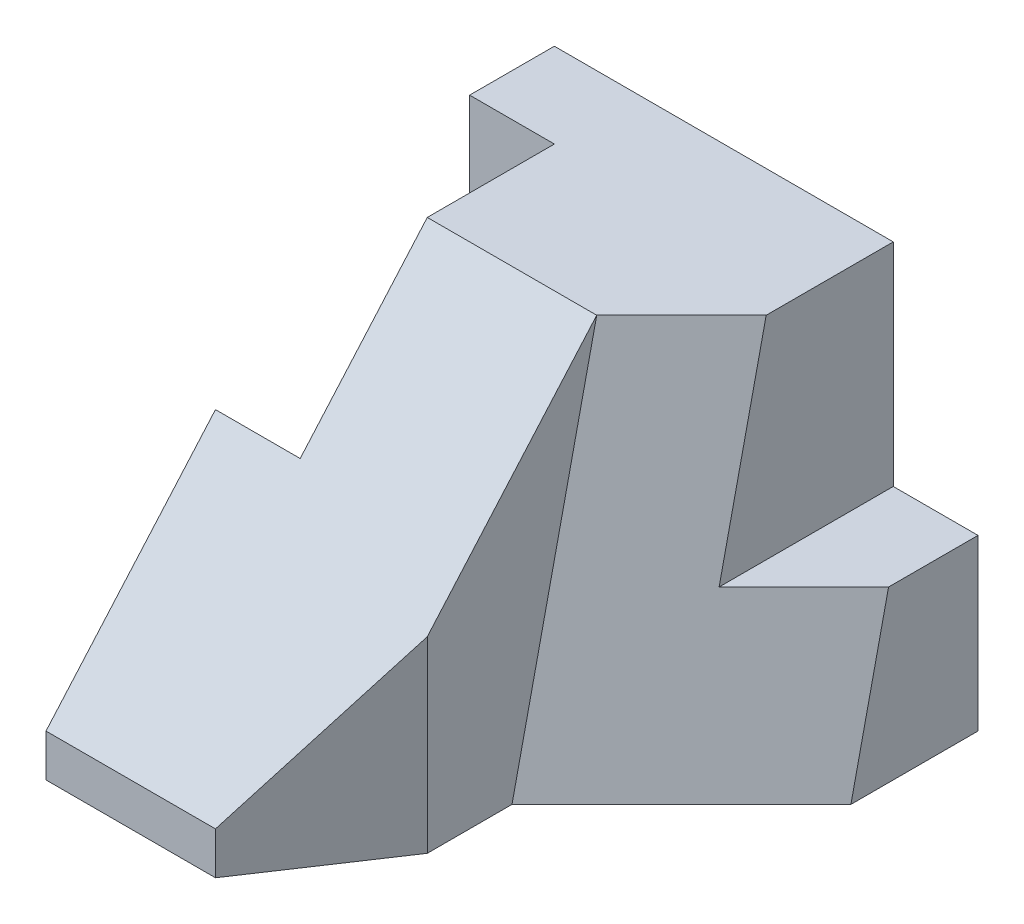
from build123d import *

# Parameters (mm, degrees)
SKETCH1_W            = 80
SKETCH1_H            = 50
BOSS_EXTRUDE1_DEPTH  = 90
SKETCH2_W            = 20
SKETCH2_H            = 30
CUT_EXTRUDE1_DEPTH   = 90
BOSS_EXTRUDE2_DEPTH  = 20
CUT_EXTRUDE2_DEPTH   = 127
BOSS_EXTRUDE10_DEPTH = 38
BOSS_EXTRUDE16_DEPTH = 38
BOSS_EXTRUDE17_DEPTH = 38
SKETCH13_W           = 30
SKETCH13_H           = 50
CUT_EXTRUDE4_DEPTH   = 38
SKETCH14_W           = 100
SKETCH14_H           = 90
CUT_EXTRUDE5_DEPTH   = 38
SKETCH15_W           = 106.776830175
SKETCH15_H           = 78.518203409
CUT_EXTRUDE6_DEPTH   = 38
BOSS_EXTRUDE18_DEPTH = 10
CUT_EXTRUDE7_DEPTH   = 10
BOSS_EXTRUDE19_DEPTH = 112
SKETCH19_W           = 80
SKETCH19_H           = 90
CUT_EXTRUDE8_DEPTH   = 112
SKETCH20_W           = 107.666200856
SKETCH20_H           = 176.074092784
CUT_EXTRUDE9_DEPTH   = 112
SKETCH21_W           = 20
SKETCH21_H           = 60
CUT_EXTRUDE10_DEPTH  = 112
SKETCH27_W           = 22.568644797
SKETCH27_H           = 9.839278278
BOSS_EXTRUDE22_DEPTH = 20
BOSS_EXTRUDE24_DEPTH = 91
SKETCH32_W           = 16.460176991
SKETCH32_H           = 60
CUT_EXTRUDE13_DEPTH  = 101
CUT_EXTRUDE14_DEPTH  = 101
BOSS_EXTRUDE25_DEPTH = 5
SKETCH35_W           = 20
SKETCH35_H           = 60
CUT_EXTRUDE15_DEPTH  = 152
BOSS_EXTRUDE27_DEPTH = 20
SKETCH42_W           = 25
SKETCH42_H           = 10
BOSS_EXTRUDE29_DEPTH = 20
BOSS_EXTRUDE30_DEPTH = 20
BOSS_EXTRUDE31_DEPTH = 20
SKETCH46_W           = 60
SKETCH46_H           = 50
CUT_EXTRUDE19_DEPTH  = 20
CUT_EXTRUDE20_DEPTH  = 20
CUT_EXTRUDE21_DEPTH  = 10


with BuildPart() as part:
    # Sketch1 → Boss-Extrude1 (new body)
    with BuildSketch(Plane(origin=(0, 0, 0), x_dir=(1, 0, 0), z_dir=(0, 1, 0))):
        with Locations((40, 25)):
            Rectangle(SKETCH1_W, SKETCH1_H)
    extrude(amount=BOSS_EXTRUDE1_DEPTH)

    # Sketch2 → Cut-Extrude1 (cut)
    with BuildSketch(Plane(origin=(0, 90, 0), x_dir=(1, 0, 0), z_dir=(0, 1, 0))):
        with Locations((10, 15)):
            Rectangle(SKETCH2_W, SKETCH2_H)
    extrude(amount=-CUT_EXTRUDE1_DEPTH, mode=Mode.SUBTRACT)

    # Sketch3 → Boss-Extrude2 (add)
    with BuildSketch(Plane(origin=(80, 0, 0), x_dir=(0, 0, -1), z_dir=(1, 0, 0))):
        Polygon((20, 0), (50, 0), (50, 40), (30, 40), align=None)
    extrude(amount=BOSS_EXTRUDE2_DEPTH)

    # Sketch4 → Cut-Extrude2 (cut)
    with BuildSketch(Plane(origin=(0, 90, 0), x_dir=(1, 0, 0), z_dir=(0, 1, 0))):
        Polygon((60, 0), (80, 20), (80, 0), align=None)
    extrude(amount=-CUT_EXTRUDE2_DEPTH, mode=Mode.SUBTRACT)

    # Sketch7 → Boss-Extrude10 (add)
    with BuildSketch(Plane(origin=(38.787878788, 9.696969697, 38.787878788), x_dir=(0.717740563, -0.168880132, -0.675520529), z_dir=(0.696310624, 0.174077656, 0.696310624))):
        Polygon((29.554023164, -4.850712501), (85.284466846, 4.850712501), (85.284466846, 46.081768757), align=None)
    extrude(amount=-BOSS_EXTRUDE10_DEPTH)

    # Sketch10 → Boss-Extrude16 (add)
    with BuildSketch(Plane(origin=(39.036144578, 8.674698795, 39.036144578), x_dir=(0.715575428, -0.15153362, -0.68190129), z_dir=(0.698535473, 0.155230105, 0.698535473))):
        Polygon((57.246034218, 92.195444573), (15.321732688, 85.687530838), (29.296499865, -4.338609156), (85.195568572, 4.338609156), (85.195568572, 46.23657111), align=None)
    extrude(amount=-BOSS_EXTRUDE16_DEPTH)

    # Sketch11 → Boss-Extrude17 (add)
    with BuildSketch(Plane(origin=(100, 0, 0), x_dir=(0, 0, -1), z_dir=(1, 0, 0))):
        Polygon((20, 0), (29.088944068, 40.900248307), (30, 40), align=None)
    extrude(amount=-BOSS_EXTRUDE17_DEPTH)

    # Sketch13 → Cut-Extrude4 (cut)
    with BuildSketch(Plane(origin=(80, 0, 0), x_dir=(0, 0, -1), z_dir=(1, 0, 0))):
        with Locations((35, 65)):
            Rectangle(SKETCH13_W, SKETCH13_H)
    extrude(amount=CUT_EXTRUDE4_DEPTH, mode=Mode.SUBTRACT)

    # Sketch14 → Cut-Extrude5 (cut)
    with BuildSketch(Plane(origin=(0, 0, -50), x_dir=(-1, 0, 0), z_dir=(0, 0, -1))):
        with Locations((-50, 45)):
            Rectangle(SKETCH14_W, SKETCH14_H)
    extrude(amount=CUT_EXTRUDE5_DEPTH, mode=Mode.SUBTRACT)

    # Sketch15 → Cut-Extrude6 (cut)
    with BuildSketch(Plane.XZ):
        with Locations((53.388415088, -10.740898295)):
            Rectangle(SKETCH15_W, SKETCH15_H)
    extrude(amount=CUT_EXTRUDE6_DEPTH, mode=Mode.SUBTRACT)

    # Sketch16 → Boss-Extrude18 (add)
    with BuildSketch(Plane(origin=(0, 0, 0), x_dir=(-1, 0, 0), z_dir=(0, -1, 0))):
        Polygon((-60, -20), (-60, -40), (-40, -70), (0, -70), (0, -30), (-20, -30), (-20, 0), (-40, 0), align=None)
    extrude(amount=-BOSS_EXTRUDE18_DEPTH)

    # Sketch17 → Cut-Extrude7 (cut)
    with BuildSketch(Plane(origin=(0, 39.026548673, 44.601769912), x_dir=(-1, 0, 0), z_dir=(0, -0.658504608, -0.752576695))):
        Polygon((-20, 67.731902524), (0, -38.569555604), (-40, -38.569555604), (-60, 67.731902524), align=None)
    extrude(amount=-CUT_EXTRUDE7_DEPTH, mode=Mode.SUBTRACT)

    # Sketch18 → Boss-Extrude19 (add)
    with BuildSketch(Plane(origin=(0, 39.026548673, 44.601769912), x_dir=(-1, 0, 0), z_dir=(0, -0.658504608, -0.752576695))):
        Polygon((-20, 67.731902524), (-60, 67.731902524), (-40, -38.569555604), (0, -38.569555604), align=None)
    extrude(amount=BOSS_EXTRUDE19_DEPTH)

    # Sketch19 → Cut-Extrude8 (cut)
    with BuildSketch(Plane(origin=(0, 0, -50), x_dir=(-1, 0, 0), z_dir=(0, 0, -1))):
        with Locations((-40, 45)):
            Rectangle(SKETCH19_W, SKETCH19_H)
    extrude(amount=CUT_EXTRUDE8_DEPTH, mode=Mode.SUBTRACT)

    # Sketch20 → Cut-Extrude9 (cut)
    with BuildSketch(Plane.XZ):
        with Locations((53.833100428, -18.037046392)):
            Rectangle(SKETCH20_W, SKETCH20_H)
    extrude(amount=CUT_EXTRUDE9_DEPTH, mode=Mode.SUBTRACT)

    # Sketch21 → Cut-Extrude10 (cut)
    with BuildSketch(Plane(origin=(0, 0, 0), x_dir=(-1, 0, 0), z_dir=(0, -1, 0))):
        with Locations((-10, 0)):
            Rectangle(SKETCH21_W, SKETCH21_H)
    extrude(amount=-CUT_EXTRUDE10_DEPTH, mode=Mode.SUBTRACT)

    # Sketch27 → Boss-Extrude22 (add)
    with BuildSketch(Plane(origin=(60, 0, 0), x_dir=(0, 0, -1), z_dir=(1, 0, 0))):
        with Locations((-28.715677602, 4.919639139)):
            Rectangle(SKETCH27_W, SKETCH27_H)
    extrude(amount=-BOSS_EXTRUDE22_DEPTH)

    # Sketch31 → Boss-Extrude24 (add)
    with BuildSketch(Plane(origin=(0, 39.026548673, 44.601769912), x_dir=(-1, 0, 0), z_dir=(0, -0.658504608, -0.752576695))):
        Polygon((0, -38.569555604), (-11.428571429, 22.174134755), (0, 22.174134755), align=None)
    extrude(amount=BOSS_EXTRUDE24_DEPTH)

    # Sketch32 → Cut-Extrude13 (cut)
    with BuildSketch(Plane(origin=(0, 0, 0), x_dir=(-1, 0, 0), z_dir=(0, -1, 0))):
        with Locations((-11.769911504, 0)):
            Rectangle(SKETCH32_W, SKETCH32_H)
    extrude(amount=-CUT_EXTRUDE13_DEPTH, mode=Mode.SUBTRACT)

    # Sketch33 → Cut-Extrude14 (cut)
    with BuildSketch(Plane(origin=(7.008547009, -0.992360638, 0.868315559), x_dir=(0.120555065, -0.017069744, -0.992559872), z_dir=(0.982757328, -0.13915148, 0.121757545))):
        Polygon((-0.652056607, -49.430869531), (39.647779316, -2.565835787), (34.800706646, 1.602223376), (-58.135649667, 0), align=None)
    extrude(amount=-CUT_EXTRUDE14_DEPTH, mode=Mode.SUBTRACT)

    # Sketch34 → Boss-Extrude25 (add)
    with BuildSketch(Plane(origin=(0, 0, 0), x_dir=(-1, 0, 0), z_dir=(0, -1, 0))):
        Polygon((0, -58.571428571), (0, -30), (-3.539823009, -30), align=None)
        Polygon((0, 36.93877551), (0, 50), (-40, 50), (-40, -70), (0, -70), (0, -58.571428571), (-3.539823009, -30), (-20, -30), (-20, 30), (-10.973451327, 30), (-11.428571429, 33.673469388), align=None)
        Polygon((0, -30), (0, 30), (-10.973451327, 30), (-20, 30), (-20, -30), (-3.539823009, -30), align=None)
        Polygon((0, 30), (0, 36.93877551), (-11.428571429, 33.673469388), (-10.973451327, 30), align=None)
    extrude(amount=-BOSS_EXTRUDE25_DEPTH)

    # Sketch35 → Cut-Extrude15 (cut)
    with BuildSketch(Plane(origin=(0, 0, 0), x_dir=(-1, 0, 0), z_dir=(0, -1, 0))):
        with Locations((-10, 0)):
            Rectangle(SKETCH35_W, SKETCH35_H)
    extrude(amount=-CUT_EXTRUDE15_DEPTH, mode=Mode.SUBTRACT)

    # Sketch39 → Boss-Extrude27 (add)
    with BuildSketch(Plane(origin=(60, 0, 40), x_dir=(0.554700196, 0, -0.832050294), z_dir=(0.832050294, 0, 0.554700196))):
        Polygon((0, 10), (0, 40), (-36.055512755, 10), align=None)
    extrude(amount=-BOSS_EXTRUDE27_DEPTH)

    # Sketch42 → Boss-Extrude29 (add)
    with BuildSketch(Plane(origin=(60, 0, 0), x_dir=(0, 0, -1), z_dir=(1, 0, 0))):
        with Locations((-27.5, 5)):
            Rectangle(SKETCH42_W, SKETCH42_H)
    extrude(amount=-BOSS_EXTRUDE29_DEPTH)

    # Sketch43 → Boss-Extrude30 (add)
    with BuildSketch(Plane(origin=(60, 0, 0), x_dir=(0, 0, -1), z_dir=(1, 0, 0))):
        Polygon((-40, 10), (-17.777777778, 10), (0, 90), (-40, 40), align=None)
    extrude(amount=-BOSS_EXTRUDE30_DEPTH)

    # Sketch44 → Boss-Extrude31 (add)
    with BuildSketch(Plane(origin=(0, 39.026548673, 44.601769912), x_dir=(1, 0, 0), z_dir=(0, 0.658504608, 0.752576695))):
        Polygon((40, -38.569555604), (60, 67.731902524), (60, 3.762883474), align=None)
    extrude(amount=-BOSS_EXTRUDE31_DEPTH)

    # Sketch46 → Cut-Extrude19 (cut)
    with BuildSketch(Plane(origin=(0, 0, 0), x_dir=(-1, 0, 0), z_dir=(0, -1, 0))):
        with Locations((-30, -45)):
            Rectangle(SKETCH46_W, SKETCH46_H)
    extrude(amount=CUT_EXTRUDE19_DEPTH, mode=Mode.SUBTRACT)

    # Sketch47 → Cut-Extrude20 (cut)
    with BuildSketch(Plane(origin=(0, 0, -20), x_dir=(-1, 0, 0), z_dir=(0, 0, -1))):
        Polygon((-80, 90), (-80, 40), (-91.111111111, 40), align=None)
    extrude(amount=-CUT_EXTRUDE20_DEPTH, mode=Mode.SUBTRACT)

    # Sketch48 → Cut-Extrude21 (cut)
    with BuildSketch(Plane(origin=(60, 0, 40), x_dir=(0.554700196, 0, -0.832050294), z_dir=(0.832050294, 0, 0.554700196))):
        Polygon((0, 0), (0, 64.446209383), (-38.036246254, 32.223104692), (-36.055512755, 0), align=None)
    extrude(amount=CUT_EXTRUDE21_DEPTH, mode=Mode.SUBTRACT)


solid = part.part
